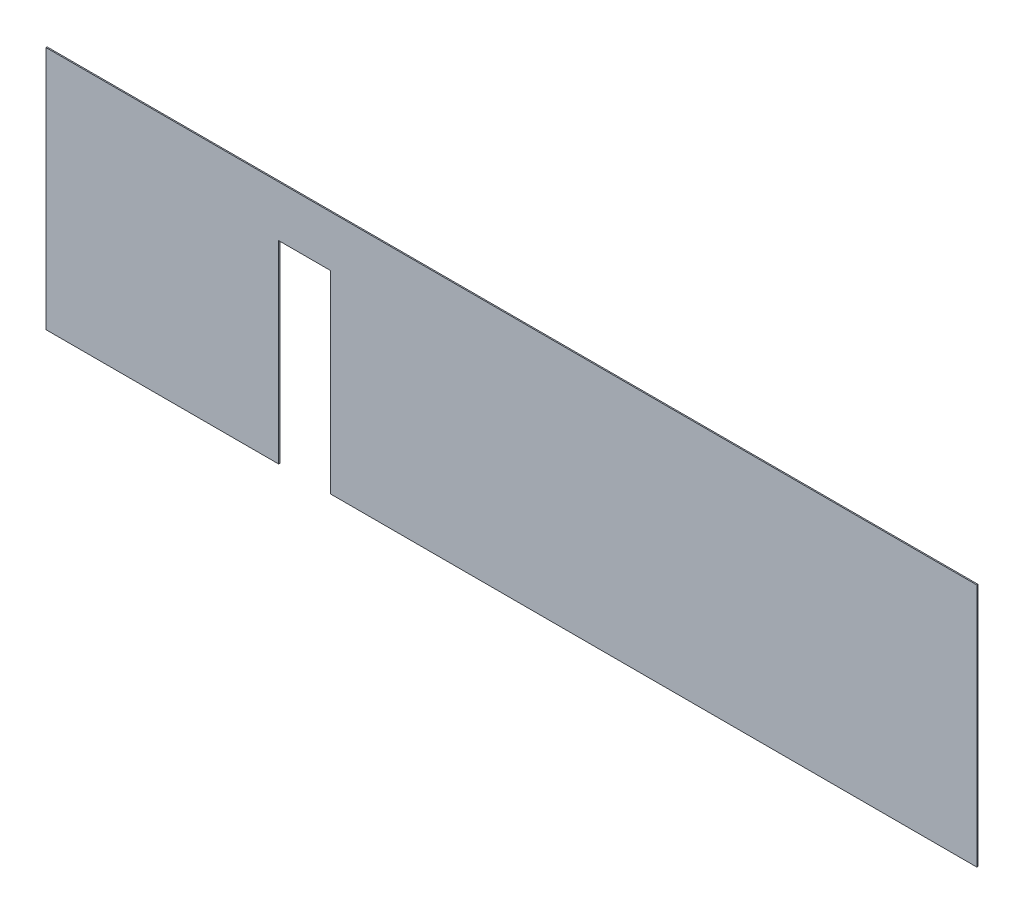
from build123d import *

# Parameters (mm, degrees)
SKETCH1_W           = 8000
SKETCH1_H           = 2100
BOSS_EXTRUDE1_DEPTH = 10
SKETCH2_W           = 447
SKETCH2_H           = 1663
CUT_EXTRUDE1_DEPTH  = 11


with BuildPart() as part:
    # Sketch1 → Boss-Extrude1 (new body)
    with BuildSketch(Plane.XY):
        Rectangle(SKETCH1_W, SKETCH1_H)
    extrude(amount=BOSS_EXTRUDE1_DEPTH)

    # Sketch2 → Cut-Extrude1 (cut, through all)
    with BuildSketch(Plane.XY.offset(10)):
        with Locations((-1776.5, -218.5)):
            Rectangle(SKETCH2_W, SKETCH2_H)
    extrude(amount=-CUT_EXTRUDE1_DEPTH, mode=Mode.SUBTRACT)


solid = part.part
